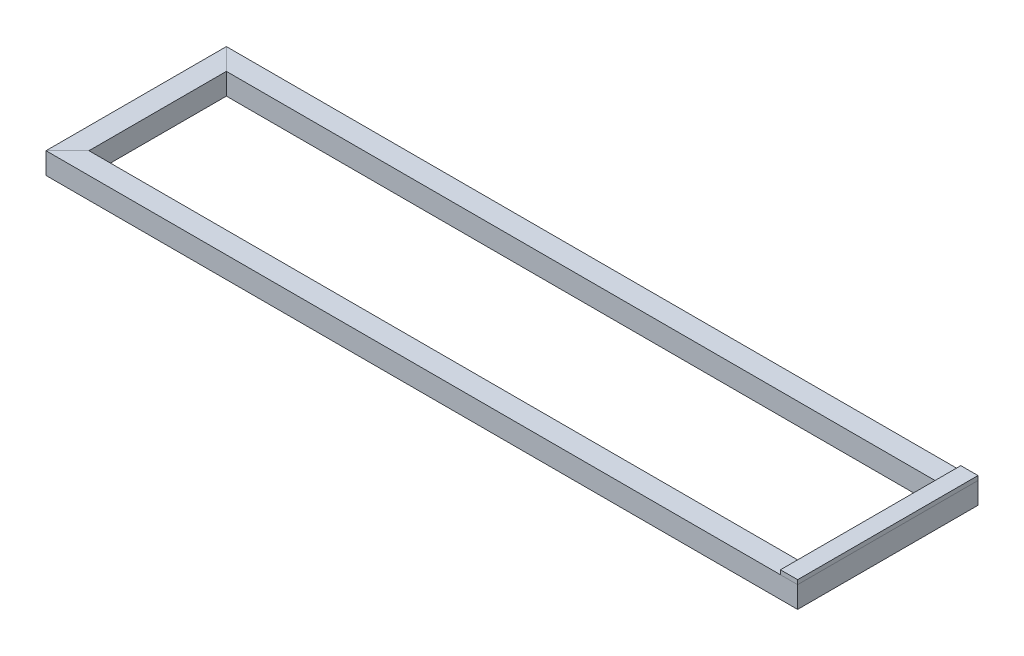
from build123d import *

# Parameters (mm, degrees)
SKETCH17_W                            = 50
SKETCH17_H                            = 50
SQUARE_BAR_SQUARE_BAR_50_1_DEPTH      = 406.355339059
SQUARE_BAR_SQUARE_BAR_50_1_DEPTH_BACK = 36.355339059
SKETCH17_ON_SEGMENT_2_W               = 50
SKETCH17_ON_SEGMENT_2_H               = 50
SQUARE_BAR_SQUARE_BAR_50_1_2_DEPTH    = 1772.710678119
SKETCH17_ON_SEGMENT_3_W               = 50
SKETCH17_ON_SEGMENT_3_H               = 50
SQUARE_BAR_SQUARE_BAR_50_1_3_DEPTH    = 442.710678119
SKETCH17_ON_SEGMENT_4_W               = 50
SKETCH17_ON_SEGMENT_4_H               = 50
SQUARE_BAR_SQUARE_BAR_50_1_4_DEPTH    = 1772.710678119
SKETCH_13_W                           = 40
SKETCH_13_H                           = 420
EXTRUDE_2_DEPTH                       = 10


with BuildPart() as part:
    # Sketch17 → Square bar SQUARE BAR 50(1) (new, two sides)
    with BuildSketch(Plane(origin=(-850, 0, -185), x_dir=(1, 0, 0), z_dir=(0, 0, 1))) as square_bar_square_bar_50_1_sk:
        Rectangle(SKETCH17_W, SKETCH17_H)
    extrude(amount=SQUARE_BAR_SQUARE_BAR_50_1_DEPTH)
    extrude(square_bar_square_bar_50_1_sk.sketch, amount=-SQUARE_BAR_SQUARE_BAR_50_1_DEPTH_BACK)

    # Square bar SQUARE BAR 50(1) mitre 1
    split(bisect_by=Plane(origin=(-850, 0, -185), x_dir=(0, -1, 0), z_dir=(-0.707106781, 0, 0.707106781)), keep=Keep.TOP)

    # Square bar SQUARE BAR 50(1) mitre 2
    split(bisect_by=Plane(origin=(-850, 0, 185), x_dir=(0, -1, 0), z_dir=(-0.707106781, 0, -0.707106781)), keep=Keep.TOP)


with BuildPart() as body_2:
    # Sketch17 on segment 2 (carried to segment 2) → Square bar SQUARE BAR 50_1 2 (new body)
    with BuildSketch(Plane(origin=(-886.355339059, 0, 185), x_dir=(0, 0, -1), z_dir=(1, 0, 0))):
        Rectangle(SKETCH17_ON_SEGMENT_2_W, SKETCH17_ON_SEGMENT_2_H)
    extrude(amount=SQUARE_BAR_SQUARE_BAR_50_1_2_DEPTH)

    # Square bar SQUARE BAR 50_1 2 mitre 1
    split(bisect_by=Plane(origin=(-850, 0, 185), x_dir=(0, 1, 0), z_dir=(0.707106781, 0, 0.707106781)), keep=Keep.TOP)

    # Square bar SQUARE BAR 50_1 2 mitre 2
    split(bisect_by=Plane(origin=(850, 0, 185), x_dir=(0, -1, 0), z_dir=(-0.707106781, 0, 0.707106781)), keep=Keep.TOP)


with BuildPart() as body_3:
    # Sketch17 on segment 3 (carried to segment 3) → Square bar SQUARE BAR 50_1 3 (new body)
    with BuildSketch(Plane(origin=(850, 0, 221.355339059), x_dir=(-1, 0, 0), z_dir=(0, 0, -1))):
        Rectangle(SKETCH17_ON_SEGMENT_3_W, SKETCH17_ON_SEGMENT_3_H)
    extrude(amount=SQUARE_BAR_SQUARE_BAR_50_1_3_DEPTH)

    # Square bar SQUARE BAR 50_1 3 mitre 1
    split(bisect_by=Plane(origin=(850, 0, -185), x_dir=(0, 1, 0), z_dir=(0.707106781, 0, 0.707106781)), keep=Keep.TOP)

    # Square bar SQUARE BAR 50_1 3 mitre 2
    split(bisect_by=Plane(origin=(850, 0, 185), x_dir=(0, 1, 0), z_dir=(0.707106781, 0, -0.707106781)), keep=Keep.TOP)


with BuildPart() as body_4:
    # Sketch17 on segment 4 (carried to segment 4) → Square bar SQUARE BAR 50_1 4 (new body)
    with BuildSketch(Plane(origin=(886.355339059, 0, -185), x_dir=(0, 0, 1), z_dir=(-1, 0, 0))):
        Rectangle(SKETCH17_ON_SEGMENT_4_W, SKETCH17_ON_SEGMENT_4_H)
    extrude(amount=SQUARE_BAR_SQUARE_BAR_50_1_4_DEPTH)

    # Square bar SQUARE BAR 50_1 4 mitre 1
    split(bisect_by=Plane(origin=(-850, 0, -185), x_dir=(0, 1, 0), z_dir=(0.707106781, 0, -0.707106781)), keep=Keep.TOP)

    # Square bar SQUARE BAR 50_1 4 mitre 2
    split(bisect_by=Plane(origin=(850, 0, -185), x_dir=(0, -1, 0), z_dir=(-0.707106781, 0, -0.707106781)), keep=Keep.TOP)


with BuildPart() as body_5:
    # 草图13 → 凸台-拉伸2 (new body)
    with BuildSketch(Plane(origin=(0, 25, 0), x_dir=(1, 0, 0), z_dir=(0, 1, 0))):
        with Locations((855, 0)):
            Rectangle(SKETCH_13_W, SKETCH_13_H)
    extrude(amount=EXTRUDE_2_DEPTH)


solid = Compound([part.part, body_2.part, body_3.part, body_4.part, body_5.part])
